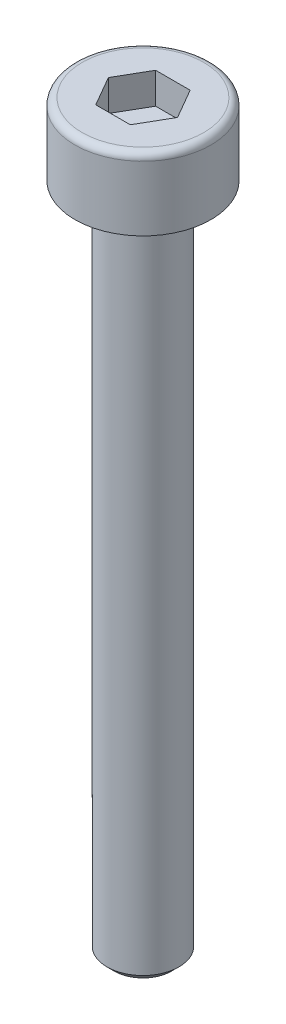
from build123d import *

# Parameters (mm, degrees)
SKETCH_1_R          = 2.84
EXTRUDE_1_DEPTH     = 3
CUT_EXTRUDE_1_DEPTH = 1.3
SKETCH_3_R          = 1.5
EXTRUDE_2_DEPTH     = 28
CHAMFER_1_SIZE      = 0.3
FILLET_1_R          = 0.3
CHAMFER_2_SIZE      = 0.1


with BuildPart() as part:
    # 草图1 → 凸台-拉伸1 (new body)
    with BuildSketch(Plane(origin=(0, 0, 0), x_dir=(1, 0, 0), z_dir=(0, 1, 0))):
        Circle(SKETCH_1_R)
    extrude(amount=EXTRUDE_1_DEPTH)

    # 草图2 → 切除-拉伸1 (cut)
    with BuildSketch(Plane(origin=(0, 3, 0), x_dir=(1, 0, 0), z_dir=(0, 1, 0))):
        Polygon((1.443375673, 0), (0.721687836, 1.25), (-0.721687836, 1.25), (-1.443375673, 0), (-0.721687836, -1.25), (0.721687836, -1.25), align=None)
    extrude(amount=-CUT_EXTRUDE_1_DEPTH, mode=Mode.SUBTRACT)

    # 草图3 → 凸台-拉伸2 (add)
    with BuildSketch(Plane.XZ):
        Circle(SKETCH_3_R)
    extrude(amount=EXTRUDE_2_DEPTH)

    # 倒角1
    chamfer_1_edges = [part.edges().sort_by_distance(p)[0] for p in [
        (-1.5, -28, 0),
    ]]
    chamfer(chamfer_1_edges, length=CHAMFER_1_SIZE)

    # 圆角1
    fillet_1_edges = [part.edges().sort_by_distance(p)[0] for p in [
        (-2.84, 3, 0),
    ]]
    fillet(fillet_1_edges, radius=FILLET_1_R)

    # 倒角2
    chamfer_2_edges = [part.edges().sort_by_distance(p)[0] for p in [
        (-1.5, 0, 0),
    ]]
    chamfer(chamfer_2_edges, length=CHAMFER_2_SIZE)


solid = part.part
